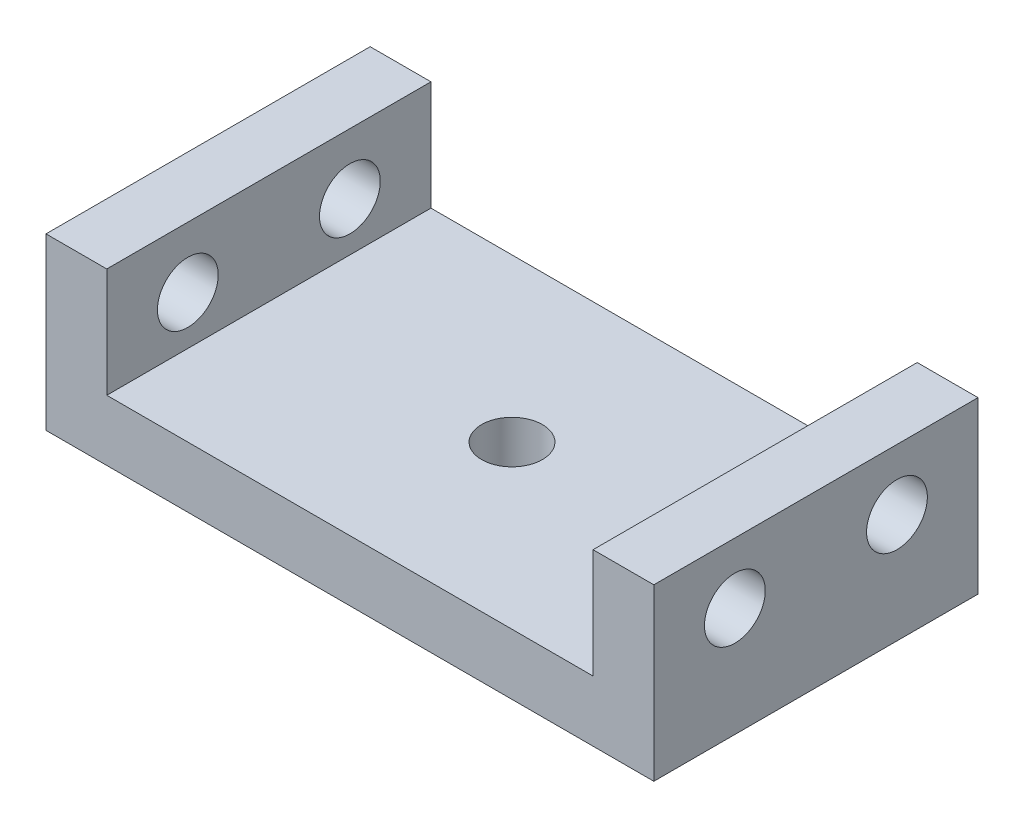
from build123d import *

# Parameters (mm, degrees)
SKETCH1_W           = 30
SKETCH1_H           = 16
BOSS_EXTRUDE1_DEPTH = 3
SKETCH2_W           = 3
SKETCH2_H           = 16
BOSS_EXTRUDE2_DEPTH = 5.4
SKETCH3_R           = 1.5
CUT_EXTRUDE1_DEPTH  = 5.4
SKETCH4_R           = 1.5
CUT_EXTRUDE2_DEPTH  = 10


with BuildPart() as part:
    # Sketch1 → Boss-Extrude1 (new body)
    with BuildSketch(Plane(origin=(0, 0, 0), x_dir=(1, 0, 0), z_dir=(0, 1, 0))):
        Rectangle(SKETCH1_W, SKETCH1_H)
    extrude(amount=BOSS_EXTRUDE1_DEPTH)

    # Sketch2 → Boss-Extrude2 (add)
    with BuildSketch(Plane(origin=(0, 3, 0), x_dir=(1, 0, 0), z_dir=(0, 1, 0))):
        with Locations((-13.5, 0)):
            Rectangle(SKETCH2_W, SKETCH2_H)
    boss_extrude2 = extrude(amount=BOSS_EXTRUDE2_DEPTH)

    # Sketch3 → Cut-Extrude1 (cut)
    with BuildSketch(Plane.ZY.offset(15)):
        with Locations((-4, 5.4)):
            Circle(SKETCH3_R)
        with Locations((4, 5.4)):
            Circle(SKETCH3_R)
    cut_extrude1 = extrude(amount=-CUT_EXTRUDE1_DEPTH, mode=Mode.SUBTRACT)

    # Mirror1: Boss-Extrude2, Cut-Extrude1 across plane
    add(boss_extrude2.mirror(Plane(origin=(0, 0, 0), x_dir=(0, 0, 1), z_dir=(1, 0, 0))))
    add(cut_extrude1.mirror(Plane(origin=(0, 0, 0), x_dir=(0, 0, 1), z_dir=(1, 0, 0))), mode=Mode.SUBTRACT)

    # Sketch4 → Cut-Extrude2 (cut)
    with BuildSketch(Plane(origin=(0, 3, 0), x_dir=(1, 0, 0), z_dir=(0, 1, 0))):
        Circle(SKETCH4_R)
    extrude(amount=-CUT_EXTRUDE2_DEPTH, mode=Mode.SUBTRACT)


solid = part.part
